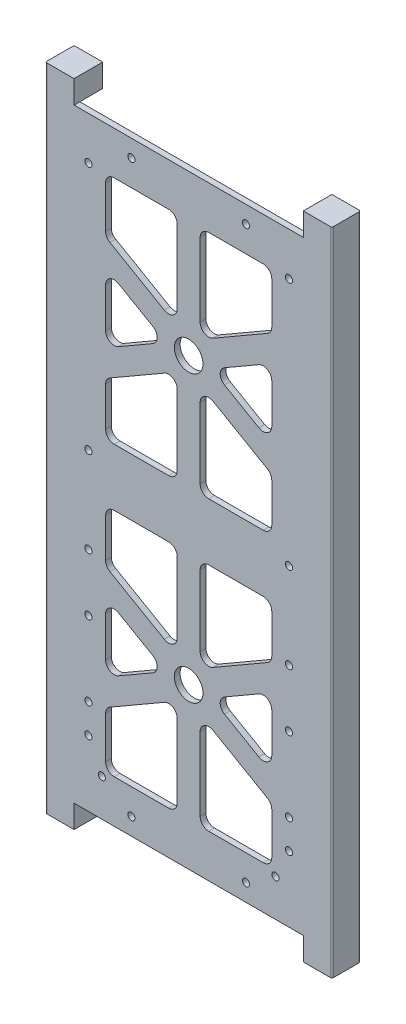
from build123d import *

# Parameters (mm, degrees)
SKETCH1_W                      = 88
SKETCH1_H                      = 211
BOSS_EXTRUDE1_DEPTH            = 2
CUT_EXTRUDE2_DEPTH             = 2
SKETCH4_R                      = 5
CUT_EXTRUDE3_DEPTH             = 3
FILLET2_R                      = 3
BOSS_EXTRUDE2_DEPTH            = 10
CUT_EXTRUDE5_DEPTH             = 8
M3X0_5_TAPPED_HOLE1_AT_2_COUNT = 2
M3X0_5_TAPPED_HOLE1_AT_2_PITCH = 30
M3X0_5_TAPPED_HOLE1_AT_3_COUNT = 2
M3X0_5_TAPPED_HOLE1_AT_3_PITCH = 50
M3X0_5_TAPPED_HOLE1_AT_4_COUNT = 2
M3X0_5_TAPPED_HOLE1_AT_4_PITCH = 76
M3X0_5_TAPPED_HOLE1_AT_5_COUNT = 2
M3X0_5_TAPPED_HOLE1_AT_5_PITCH = 96.314744458
M3X0_5_TAPPED_HOLE1_AT_6_COUNT = 2
M3X0_5_TAPPED_HOLE1_AT_6_PITCH = 96.967210953
M3X0_5_TAPPED_HOLE1_AT_7_COUNT = 2
M3X0_5_TAPPED_HOLE1_AT_7_PITCH = 104.284418779
M3X0_5_TAPPED_HOLE1_AT_8_COUNT = 2
M3X0_5_TAPPED_HOLE1_AT_8_PITCH = 86.2
M3X0_5_TAPPED_HOLE1_AT_9_COUNT = 2
M3X0_5_TAPPED_HOLE1_AT_9_PITCH = 86.8
SKETCH58_R                     = 1.665
CUT_EXTRUDE9_DEPTH             = 1.8
SKETCH59_R                     = 2
CUT_EXTRUDE10_DEPTH            = 10
FILLET3_R                      = 0.5


with BuildPart() as part:
    # Sketch1 → Boss-Extrude1 (new body)
    with BuildSketch(Plane.XY):
        with Locations((44, 105.5)):
            Rectangle(SKETCH1_W, SKETCH1_H)
    extrude(amount=BOSS_EXTRUDE1_DEPTH)

    # Sketch3 → Cut-Extrude2 (cut)
    with BuildSketch(Plane.XY.offset(2)):
        Polygon((73, 115.5), (73, 133.88804004), (48, 148.32179677), (48, 115.5), align=None)
        Polygon((40, 148.32179677), (15, 133.88804004), (15, 115.5), (40, 115.5), align=None)
        Polygon((36, 155.25), (15, 167.374355653), (15, 143.125644347), align=None)
        Polygon((73, 143.125644347), (73, 167.374355653), (52, 155.25), align=None)
        Polygon((73, 196), (48, 196), (48, 162.17820323), (73, 176.61195996), align=None)
        Polygon((40, 196), (15, 196), (15, 176.61195996), (40, 162.17820323), align=None)
    cut_extrude2 = extrude(amount=-CUT_EXTRUDE2_DEPTH, mode=Mode.SUBTRACT)

    # Sketch4 → Cut-Extrude3 (cut, through all)
    with BuildSketch(Plane.XY.offset(2)):
        with Locations((44, 155.25)):
            Circle(SKETCH4_R)
    cut_extrude3 = extrude(amount=-CUT_EXTRUDE3_DEPTH, mode=Mode.SUBTRACT)

    # Mirror2: Cut-Extrude2, Cut-Extrude3 across plane
    add(cut_extrude2.mirror(Plane(origin=(0, 105.5, 0), x_dir=(0, 0, 1), z_dir=(0, -1, 0))), mode=Mode.SUBTRACT)
    add(cut_extrude3.mirror(Plane(origin=(0, 105.5, 0), x_dir=(0, 0, 1), z_dir=(0, -1, 0))), mode=Mode.SUBTRACT)

    # Fillet2
    fillet2_edges = [part.edges().sort_by_distance(p)[0] for p in [
        (36, 55.75, 1),
        (15, 43.625644347, 1),
        (15, 67.874355653, 1),
        (40, 95.5, 1),
        (40, 62.67820323, 1),
        (15, 77.11195996, 1),
        (15, 95.5, 1),
        (48, 48.82179677, 1),
        (73, 34.38804004, 1),
        (73, 15, 1),
        (48, 15, 1),
        (73, 43.625644347, 1),
        (52, 55.75, 1),
        (73, 67.874355653, 1),
        (15, 15, 1),
        (15, 34.38804004, 1),
        (40, 48.82179677, 1),
        (40, 15, 1),
        (73, 77.11195996, 1),
        (48, 62.67820323, 1),
        (48, 95.5, 1),
        (73, 95.5, 1),
        (15, 167.374355653, 1),
        (36, 155.25, 1),
        (15, 143.125644347, 1),
        (40, 148.32179677, 1),
        (40, 115.5, 1),
        (15, 115.5, 1),
        (15, 133.88804004, 1),
        (73, 176.61195996, 1),
        (48, 162.17820323, 1),
        (48, 196, 1),
        (73, 196, 1),
        (52, 155.25, 1),
        (73, 167.374355653, 1),
        (73, 143.125644347, 1),
        (15, 176.61195996, 1),
        (15, 196, 1),
        (40, 196, 1),
        (40, 162.17820323, 1),
        (48, 148.32179677, 1),
        (73, 133.88804004, 1),
        (73, 115.5, 1),
        (48, 115.5, 1),
    ]]
    fillet(fillet2_edges, radius=FILLET2_R)

    # Sketch7 → Boss-Extrude2 (add)
    with BuildSketch(Plane.XY.offset(2)):
        Polygon((94, 219), (84, 219), (84, 211), (88, 211), (88, 0), (84, 0), (84, -8), (94, -8), align=None)
        Polygon((-6, -8), (4, -8), (4, 0), (0, 0), (0, 211), (4, 211), (4, 219), (-6, 219), align=None)
    extrude(amount=-BOSS_EXTRUDE2_DEPTH)

    # Sketch53 → Cut-Extrude5 (cut)
    with BuildSketch(Plane(origin=(0, 0, -8), x_dir=(-1, 0, 0), z_dir=(0, 0, -1))):
        with BuildLine():
            Line((-90, 0), (-88, 0))
            Line((-88, 0), (-88, 211))
            Line((-88, 211), (-90, 211))
            ThreePointArc((-90, 211), (-91.414213562, 210.414213562), (-92, 209))
            Line((-92, 209), (-92, 2))
            ThreePointArc((-92, 2), (-91.414213562, 0.585786438), (-90, 0))
        make_face()
        with BuildLine():
            Line((2, 0), (-4, 0))
            Line((-4, 0), (-4, 211))
            Line((-4, 211), (2, 211))
            ThreePointArc((2, 211), (3.414213562, 210.414213562), (4, 209))
            Line((4, 209), (4, 2))
            ThreePointArc((4, 2), (3.414213562, 0.585786438), (2, 0))
        make_face()
    extrude(amount=-CUT_EXTRUDE5_DEPTH, mode=Mode.SUBTRACT)

    # Sketch56 → M3x0.5 Tapped Hole1 (revolve, cut)
    with BuildSketch(Plane(origin=(9, 109.2, 2), x_dir=(0, -1, 0), z_dir=(1, 0, 0))):
        Polygon((0, 0), (0, 10.751075774), (1.25, 10), (1.25, 0), align=None)
    m3x0_5_tapped_hole1 = revolve(axis=Axis((9, 109.2, 8.35), (0, 0, -1)), mode=Mode.SUBTRACT)

    # M3x0.5 Tapped Hole1 at 2: M3x0.5 Tapped Hole1 ×2
    with Locations(*[(0, -i * M3X0_5_TAPPED_HOLE1_AT_2_PITCH, 0) for i in range(1, M3X0_5_TAPPED_HOLE1_AT_2_COUNT)]):
        add(m3x0_5_tapped_hole1, mode=Mode.SUBTRACT)

    # M3x0.5 Tapped Hole1 at 3: M3x0.5 Tapped Hole1 ×2
    with Locations(*[(0, -i * M3X0_5_TAPPED_HOLE1_AT_3_PITCH, 0) for i in range(1, M3X0_5_TAPPED_HOLE1_AT_3_COUNT)]):
        add(m3x0_5_tapped_hole1, mode=Mode.SUBTRACT)

    # M3x0.5 Tapped Hole1 at 4: M3x0.5 Tapped Hole1 ×2
    with Locations(*[(0, -i * M3X0_5_TAPPED_HOLE1_AT_4_PITCH, 0) for i in range(1, M3X0_5_TAPPED_HOLE1_AT_4_COUNT)]):
        add(m3x0_5_tapped_hole1, mode=Mode.SUBTRACT)

    # M3x0.5 Tapped Hole1 at 5: M3x0.5 Tapped Hole1 ×2
    with Locations(*[Vector(0.048798344, -0.998808651, 0) * (i * M3X0_5_TAPPED_HOLE1_AT_5_PITCH) for i in range(1, M3X0_5_TAPPED_HOLE1_AT_5_COUNT)]):
        add(m3x0_5_tapped_hole1, mode=Mode.SUBTRACT)

    # M3x0.5 Tapped Hole1 at 6: M3x0.5 Tapped Hole1 ×2
    with Locations(*[Vector(0.154691466, 0.987962828, 0) * (i * M3X0_5_TAPPED_HOLE1_AT_6_PITCH) for i in range(1, M3X0_5_TAPPED_HOLE1_AT_6_COUNT)]):
        add(m3x0_5_tapped_hole1, mode=Mode.SUBTRACT)

    # M3x0.5 Tapped Hole1 at 7: M3x0.5 Tapped Hole1 ×2
    with Locations(*[Vector(0.143837403, -0.989601335, 0) * (i * M3X0_5_TAPPED_HOLE1_AT_7_PITCH) for i in range(1, M3X0_5_TAPPED_HOLE1_AT_7_COUNT)]):
        add(m3x0_5_tapped_hole1, mode=Mode.SUBTRACT)

    # M3x0.5 Tapped Hole1 at 8: M3x0.5 Tapped Hole1 ×2
    with Locations(*[(0, -i * M3X0_5_TAPPED_HOLE1_AT_8_PITCH, 0) for i in range(1, M3X0_5_TAPPED_HOLE1_AT_8_COUNT)]):
        add(m3x0_5_tapped_hole1, mode=Mode.SUBTRACT)

    # M3x0.5 Tapped Hole1 at 9: M3x0.5 Tapped Hole1 ×2
    with Locations(*[(0, i * M3X0_5_TAPPED_HOLE1_AT_9_PITCH, 0) for i in range(1, M3X0_5_TAPPED_HOLE1_AT_9_COUNT)]):
        add(m3x0_5_tapped_hole1, mode=Mode.SUBTRACT)

    # Mirror3: M3x0.5 Tapped Hole1 across plane
    add(m3x0_5_tapped_hole1.mirror(Plane.ZY.offset(-44)), mode=Mode.SUBTRACT)

    # Mirror3 copy 1 sketch → Mirror3 copy 1 (revolve, cut)
    with BuildSketch(Plane(origin=(79, 79.2, 2), x_dir=(0, -1, 0), z_dir=(-1, 0, 0))):
        Polygon((0, 0), (0, -10.751075774), (1.25, -10), (1.25, 0), align=None)
    revolve(axis=Axis((79, 79.2, 8.35), (0, 0, 1)), mode=Mode.SUBTRACT)

    # Mirror3 copy 2 sketch → Mirror3 copy 2 (revolve, cut)
    with BuildSketch(Plane(origin=(79, 59.2, 2), x_dir=(0, -1, 0), z_dir=(-1, 0, 0))):
        Polygon((0, 0), (0, -10.751075774), (1.25, -10), (1.25, 0), align=None)
    revolve(axis=Axis((79, 59.2, 8.35), (0, 0, 1)), mode=Mode.SUBTRACT)

    # Mirror3 copy 3 sketch → Mirror3 copy 3 (revolve, cut)
    with BuildSketch(Plane(origin=(79, 33.2, 2), x_dir=(0, -1, 0), z_dir=(-1, 0, 0))):
        Polygon((0, 0), (0, -10.751075774), (1.25, -10), (1.25, 0), align=None)
    revolve(axis=Axis((79, 33.2, 8.35), (0, 0, 1)), mode=Mode.SUBTRACT)

    # Mirror3 copy 4 sketch → Mirror3 copy 4 (revolve, cut)
    with BuildSketch(Plane(origin=(74.3, 13, 2), x_dir=(0, -1, 0), z_dir=(-1, 0, 0))):
        Polygon((0, 0), (0, -10.751075774), (1.25, -10), (1.25, 0), align=None)
    revolve(axis=Axis((74.3, 13, 8.35), (0, 0, 1)), mode=Mode.SUBTRACT)

    # Mirror3 copy 5 sketch → Mirror3 copy 5 (revolve, cut)
    with BuildSketch(Plane(origin=(64, 205, 2), x_dir=(0, -1, 0), z_dir=(-1, 0, 0))):
        Polygon((0, 0), (0, -10.751075774), (1.25, -10), (1.25, 0), align=None)
    revolve(axis=Axis((64, 205, 8.35), (0, 0, 1)), mode=Mode.SUBTRACT)

    # Mirror3 copy 6 sketch → Mirror3 copy 6 (revolve, cut)
    with BuildSketch(Plane(origin=(64, 6, 2), x_dir=(0, -1, 0), z_dir=(-1, 0, 0))):
        Polygon((0, 0), (0, -10.751075774), (1.25, -10), (1.25, 0), align=None)
    revolve(axis=Axis((64, 6, 8.35), (0, 0, 1)), mode=Mode.SUBTRACT)

    # Mirror3 copy 7 sketch → Mirror3 copy 7 (revolve, cut)
    with BuildSketch(Plane(origin=(79, 23, 2), x_dir=(0, -1, 0), z_dir=(-1, 0, 0))):
        Polygon((0, 0), (0, -10.751075774), (1.25, -10), (1.25, 0), align=None)
    revolve(axis=Axis((79, 23, 8.35), (0, 0, 1)), mode=Mode.SUBTRACT)

    # Mirror3 copy 8 sketch → Mirror3 copy 8 (revolve, cut)
    with BuildSketch(Plane(origin=(79, 196, 2), x_dir=(0, -1, 0), z_dir=(-1, 0, 0))):
        Polygon((0, 0), (0, -10.751075774), (1.25, -10), (1.25, 0), align=None)
    revolve(axis=Axis((79, 196, 8.35), (0, 0, 1)), mode=Mode.SUBTRACT)

    # Sketch58 → Cut-Extrude9 (cut)
    with BuildSketch(Plane(origin=(0, 0, 0), x_dir=(-1, 0, 0), z_dir=(0, 0, -1))):
        with Locations((-0.7, 13)):
            Circle(SKETCH58_R)
    cut_extrude9 = extrude(amount=-CUT_EXTRUDE9_DEPTH, mode=Mode.SUBTRACT)

    # Mirror4: Cut-Extrude9 across plane
    add(cut_extrude9.mirror(Plane(origin=(44, 0, 0), x_dir=(0, 0, 1), z_dir=(1, 0, 0))), mode=Mode.SUBTRACT)

    # Sketch59 → Cut-Extrude10 (cut)
    with BuildSketch(Plane(origin=(0, -8, 0), x_dir=(-1, 0, 0), z_dir=(0, -1, 0))):
        with Locations((-89, 2.4)):
            Circle(SKETCH59_R)
        with Locations((1, 2.4)):
            Circle(SKETCH59_R)
    extrude(amount=-CUT_EXTRUDE10_DEPTH, mode=Mode.SUBTRACT)

    # Fillet3
    fillet3_edges = [part.edges().sort_by_distance(p)[0] for p in [
        (94, 105.5, -8),
        (94, 105.5, 2),
        (-6, 105.5, -8),
        (-6, 105.5, 2),
    ]]
    fillet(fillet3_edges, radius=FILLET3_R)


solid = part.part
